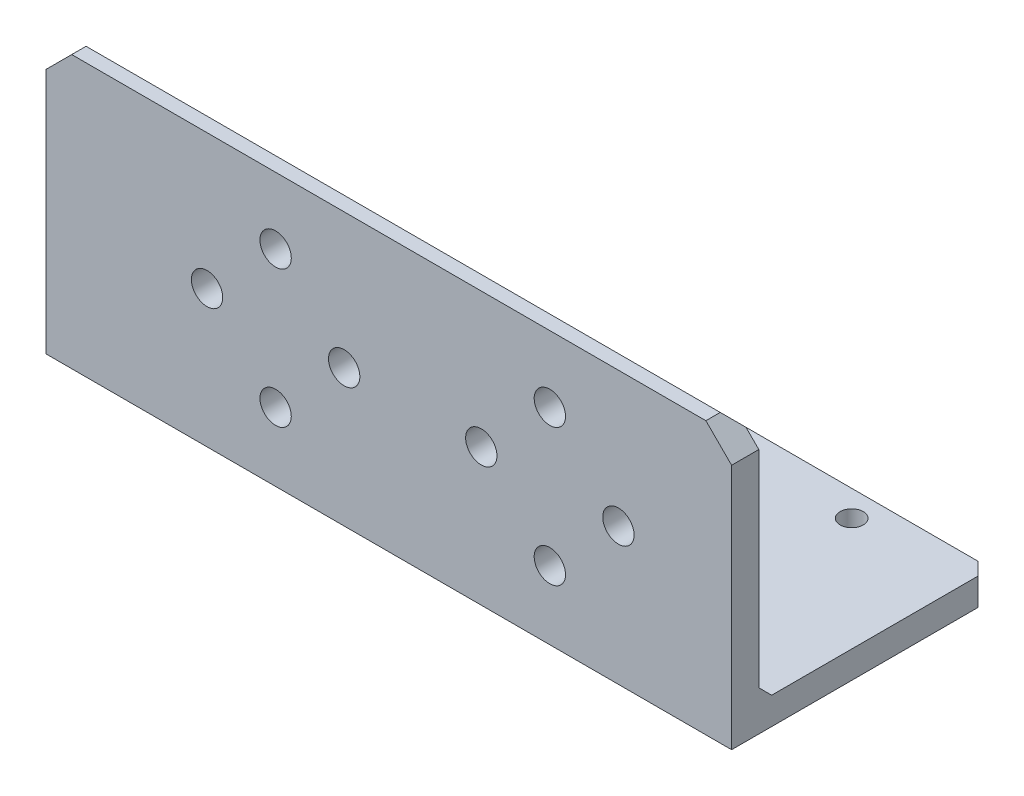
from build123d import *

# Parameters (mm, degrees)
BOSS_EXTRUDE1_DEPTH   = 40
CHAMFER1_SIZE         = 1.5
CHAMFER2_SIZE         = 3
F_6_32_TAPPED_HOLE1_D = 2.7051
F_6_CLEARANCE_HOLE1_D = 3.6576


with BuildPart() as part:
    # Sketch1 → Boss-Extrude1 (new, symmetric)
    with BuildSketch(Plane(origin=(0, 0, 0), x_dir=(0, 0, -1), z_dir=(1, 0, 0))):
        Polygon((0, 0), (31.75, 0), (31.75, 3.175), (3.175, 3.175), (3.175, 31.75), (0, 31.75), align=None)
    extrude(amount=BOSS_EXTRUDE1_DEPTH, both=True)

    # Chamfer1
    chamfer1_edges = [part.edges().sort_by_distance(p)[0] for p in [
        (0, 3.175, -31.75),
        (0, 3.175, -3.175),
        (0, 31.75, -3.175),
    ]]
    chamfer(chamfer1_edges, length=CHAMFER1_SIZE)

    # Chamfer2
    chamfer2_edges = [part.edges().sort_by_distance(p)[0] for p in [
        (-40, 31.75, -0.8375),
        (-40, 0.8375, -31.75),
        (40, 0.8375, -31.75),
        (40, 31.75, -0.8375),
    ]]
    chamfer(chamfer2_edges, length=CHAMFER2_SIZE)

    # 6-32 Tapped Hole1 (through all)
    with Locations(Plane(origin=(0, 3.175, 0), x_dir=(1, 0, 0), z_dir=(0, 1, 0))):
        with Locations((-37.208, 27.221), (10.792, 27.221), (-5.208, 27.221), (-13.208, 19.221), (-21.208, 27.221), (18.792, 19.221), (26.792, 27.221)):
            Hole(F_6_32_TAPPED_HOLE1_D / 2)

    # 6 Clearance Hole1 (through all)
    with Locations(Plane(origin=(0, 0, -3.175), x_dir=(-1, 0, 0), z_dir=(0, 0, -1))):
        with Locations((-10.792, 16), (-18.792, 8), (-18.792, 24), (-26.792, 16), (13.208, 24), (5.208, 16), (13.208, 8), (21.208, 16)):
            Hole(F_6_CLEARANCE_HOLE1_D / 2)


solid = part.part
